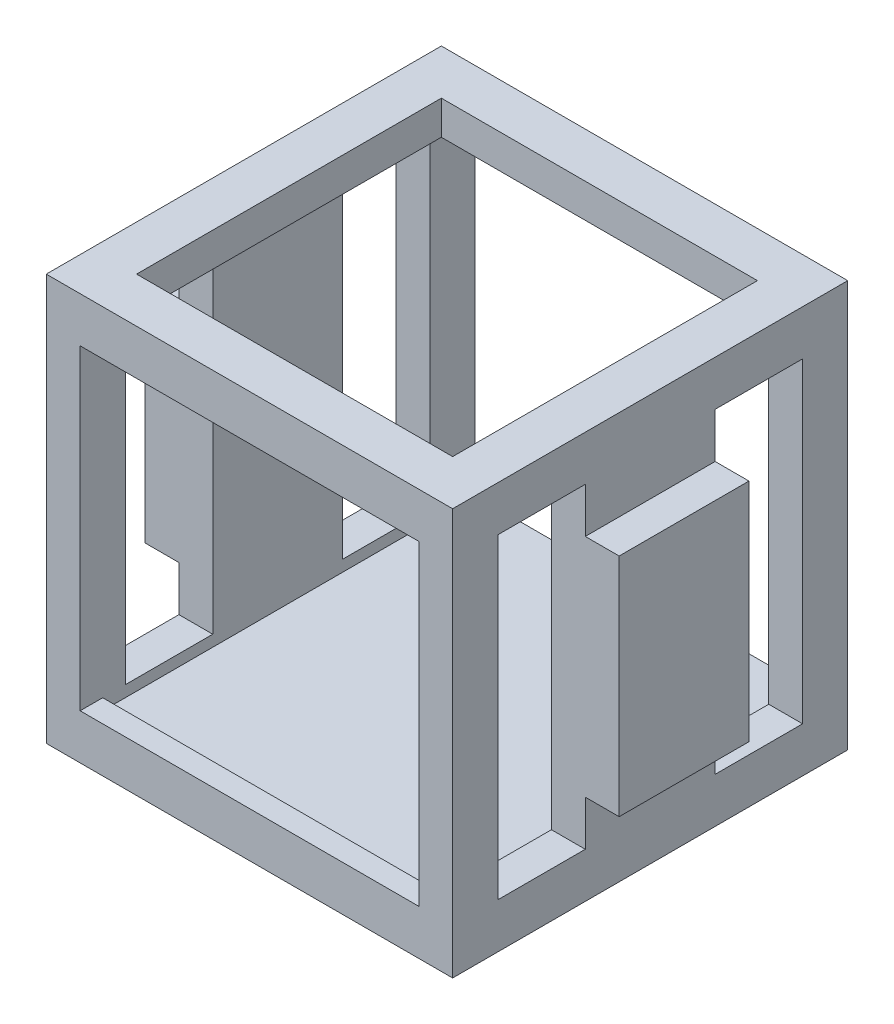
from build123d import *

# Parameters (mm, degrees)
SKETCH1_W               = 36
SKETCH1_H               = 36
BOSS_EXTRUDE1_DEPTH     = 17.5
SKETCH2_W               = 30
SKETCH2_H               = 30
CUT_EXTRUDE1_DEPTH      = 15.5
CUT_EXTRUDE1_DEPTH_BACK = 18.5
SKETCH3_W               = 30
SKETCH3_H               = 28
CUT_EXTRUDE3_DEPTH      = 36
SKETCH5_W               = 20
SKETCH5_H               = 20
BOSS_EXTRUDE2_DEPTH     = 7
CUT_EXTRUDE4_DEPTH      = 29
SKETCH7_W               = 11.5
SKETCH7_H               = 20
BOSS_EXTRUDE3_DEPTH     = 3
CUT_EXTRUDE5_DEPTH      = 32
CUT_EXTRUDE6_REACH      = 45
SKETCH10_W              = 28
SKETCH10_H              = 27
SKETCH11_W              = 7.75
SKETCH11_H              = 28
CUT_EXTRUDE7_DEPTH      = 40


with BuildPart() as part:
    # Sketch1 → Boss-Extrude1 (new body, symmetric)
    with BuildSketch(Plane.XY):
        Rectangle(SKETCH1_W, SKETCH1_H)
    extrude(amount=BOSS_EXTRUDE1_DEPTH, both=True)

    # Sketch2 → Cut-Extrude1 (cut, two sides)
    with BuildSketch(Plane.XY) as cut_extrude1_sk:
        Rectangle(SKETCH2_W, SKETCH2_H)
    extrude(amount=CUT_EXTRUDE1_DEPTH, mode=Mode.SUBTRACT)
    extrude(cut_extrude1_sk.sketch, amount=-CUT_EXTRUDE1_DEPTH_BACK, mode=Mode.SUBTRACT)

    # Sketch3 → Cut-Extrude3 (cut, through all)
    with BuildSketch(Plane.XY.offset(17.5)):
        Rectangle(SKETCH3_W, SKETCH3_H)
    extrude(amount=-CUT_EXTRUDE3_DEPTH, mode=Mode.SUBTRACT)

    # Sketch5 → Boss-Extrude2 (add)
    with BuildSketch(Plane(origin=(0, -18, 0), x_dir=(-1, 0, 0), z_dir=(0, -1, 0))):
        Rectangle(SKETCH5_W, SKETCH5_H)
    extrude(amount=BOSS_EXTRUDE2_DEPTH)

    # Sketch6 → Cut-Extrude4 (cut, through all)
    with BuildSketch(Plane(origin=(10, 0, 0), x_dir=(0, 0, -1), z_dir=(1, 0, 0))):
        with BuildLine():
            Line((-5.3, -18.5), (5.3, -18.5))
            ThreePointArc((5.3, -18.5), (0, -23.8), (-5.3, -18.5))
        make_face()
    extrude(amount=-CUT_EXTRUDE4_DEPTH, mode=Mode.SUBTRACT)

    # Sketch7 → Boss-Extrude3 (add)
    with BuildSketch(Plane(origin=(18, 0, 0), x_dir=(0, 0, -1), z_dir=(1, 0, 0))):
        Rectangle(SKETCH7_W, SKETCH7_H)
    boss_extrude3 = extrude(amount=BOSS_EXTRUDE3_DEPTH)

    # Mirror1: Boss-Extrude3 across plane
    add(boss_extrude3.mirror(Plane(origin=(0, 0, 0), x_dir=(0, 0, 1), z_dir=(1, 0, 0))))

    # Sketch9 → Cut-Extrude5 (cut, through all)
    with BuildSketch(Plane(origin=(10, 0, 0), x_dir=(0, 0, -1), z_dir=(1, 0, 0))):
        with BuildLine():
            Line((-8.3, -18.5), (-10, -18.5))
            Line((-10, -18.5), (-10, -28.666019684))
            Line((-10, -28.666019684), (10, -28.666019684))
            Line((10, -28.666019684), (10, -18.5))
            Line((10, -18.5), (8.709331347, -18.5))
            ThreePointArc((8.709331347, -18.5), (0.204665673, -27.004665673), (-8.3, -18.5))
        make_face()
    extrude(amount=-CUT_EXTRUDE5_DEPTH, mode=Mode.SUBTRACT)

    # Sketch10 → Cut-Extrude6 (cut, up to next)
    with BuildSketch(Plane(origin=(0, 18, 0), x_dir=(1, 0, 0), z_dir=(0, 1, 0)), mode=Mode.PRIVATE) as cut_extrude6_sk1:
        Rectangle(SKETCH10_W, SKETCH10_H)
    cut_extrude6_tool1 = extrude(cut_extrude6_sk1.sketch, amount=-CUT_EXTRUDE6_REACH, mode=Mode.PRIVATE) & part.part
    add(cut_extrude6_tool1.solids().sort_by_distance((0, 18, 0))[0], mode=Mode.SUBTRACT)

    # Sketch11 → Cut-Extrude7 (cut, through all)
    with BuildSketch(Plane(origin=(18, 0, 0), x_dir=(0, 0, -1), z_dir=(1, 0, 0))):
        with Locations((-9.625, 0)):
            Rectangle(SKETCH11_W, SKETCH11_H)
        with Locations((9.625, 0)):
            Rectangle(SKETCH11_W, SKETCH11_H)
    extrude(amount=-CUT_EXTRUDE7_DEPTH, mode=Mode.SUBTRACT)


solid = part.part
